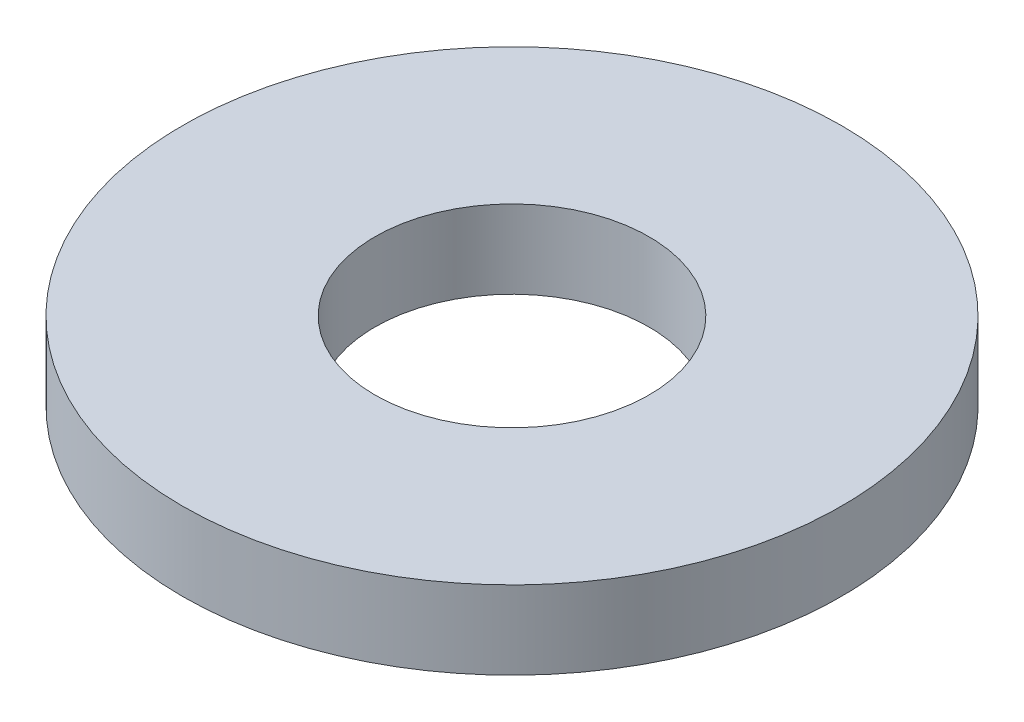
from build123d import *

# Parameters (mm, degrees)
SKETCH1_R           = 4.7625
SKETCH1_R_2         = 1.9812
BOSS_EXTRUDE1_DEPTH = 1.1303


with BuildPart() as part:
    # Sketch1 → Boss-Extrude1 (new body)
    with BuildSketch(Plane(origin=(0, 0, 0), x_dir=(1, 0, 0), z_dir=(0, 1, 0))):
        Circle(SKETCH1_R)
        Circle(SKETCH1_R_2, mode=Mode.SUBTRACT)
    extrude(amount=BOSS_EXTRUDE1_DEPTH)


solid = part.part
